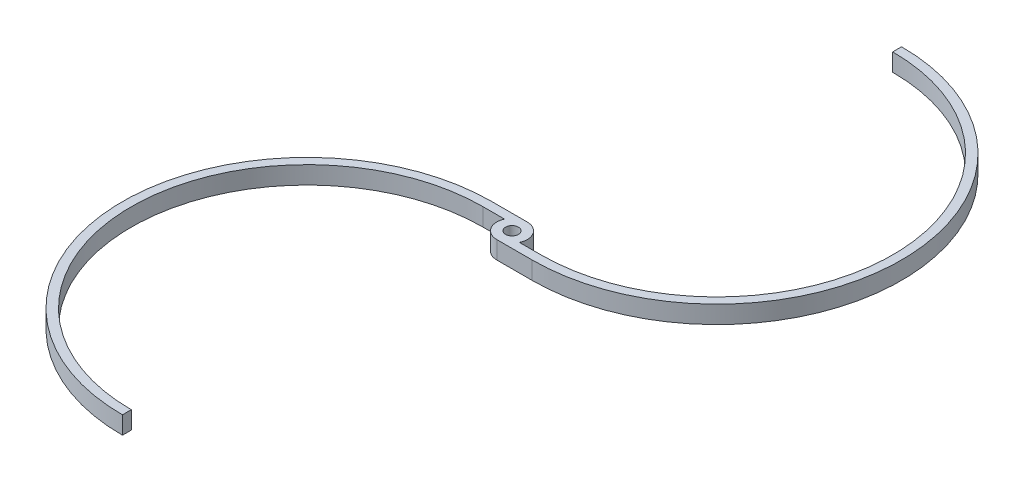
from build123d import *

# Parameters (mm, degrees)
SKETCH1_R           = 9
BOSS_EXTRUDE1_DEPTH = 25


with BuildPart() as part:
    # Sketch1 → Boss-Extrude1 (new body)
    with BuildSketch(Plane(origin=(0, 0, 0), x_dir=(1, 0, 0), z_dir=(0, 1, 0))):
        with BuildLine():
            Line((19.52562419, -9), (50, -9))
            ThreePointArc((50, -9), (298.25, 239.25), (50, 487.5))
            Line((50, 487.5), (50, 500))
            ThreePointArc((50, 500), (310.75, 239.25), (50, -21.5))
            Line((50, -21.5), (0, -21.5))
            ThreePointArc((0, -21.5), (-18.107318962, -11.592023119), (-19.52562419, 9))
            Line((-19.52562419, 9), (-50, 9))
            ThreePointArc((-50, 9), (-298.25, -239.25), (-50, -487.5))
            Line((-50, -487.5), (-50, -500))
            ThreePointArc((-50, -500), (-310.75, -239.25), (-50, 21.5))
            Line((-50, 21.5), (0, 21.5))
            ThreePointArc((0, 21.5), (18.107318962, 11.592023119), (19.52562419, -9))
        make_face()
        Circle(SKETCH1_R, mode=Mode.SUBTRACT)
    extrude(amount=BOSS_EXTRUDE1_DEPTH)


solid = part.part
